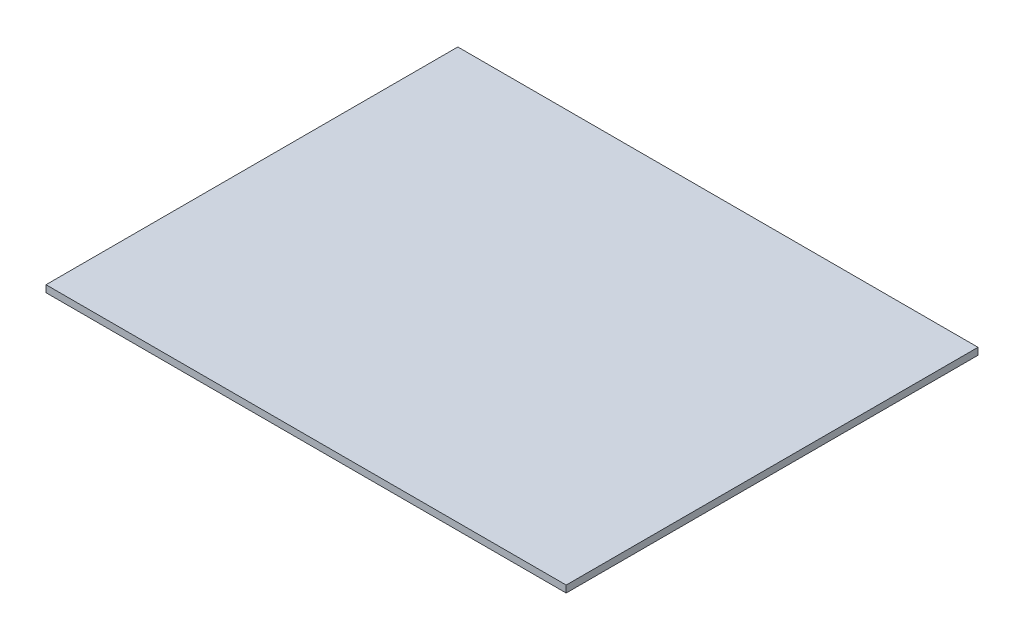
from build123d import *

# Parameters (mm, degrees)
SKETCH1_W           = 1200
SKETCH1_H           = 950
BOSS_EXTRUDE1_DEPTH = 16


with BuildPart() as part:
    # Sketch1 → Boss-Extrude1 (new body)
    with BuildSketch(Plane(origin=(0, 0, 0), x_dir=(1, 0, 0), z_dir=(0, 1, 0))):
        with Locations((600, 475)):
            Rectangle(SKETCH1_W, SKETCH1_H)
    extrude(amount=BOSS_EXTRUDE1_DEPTH)


solid = part.part
